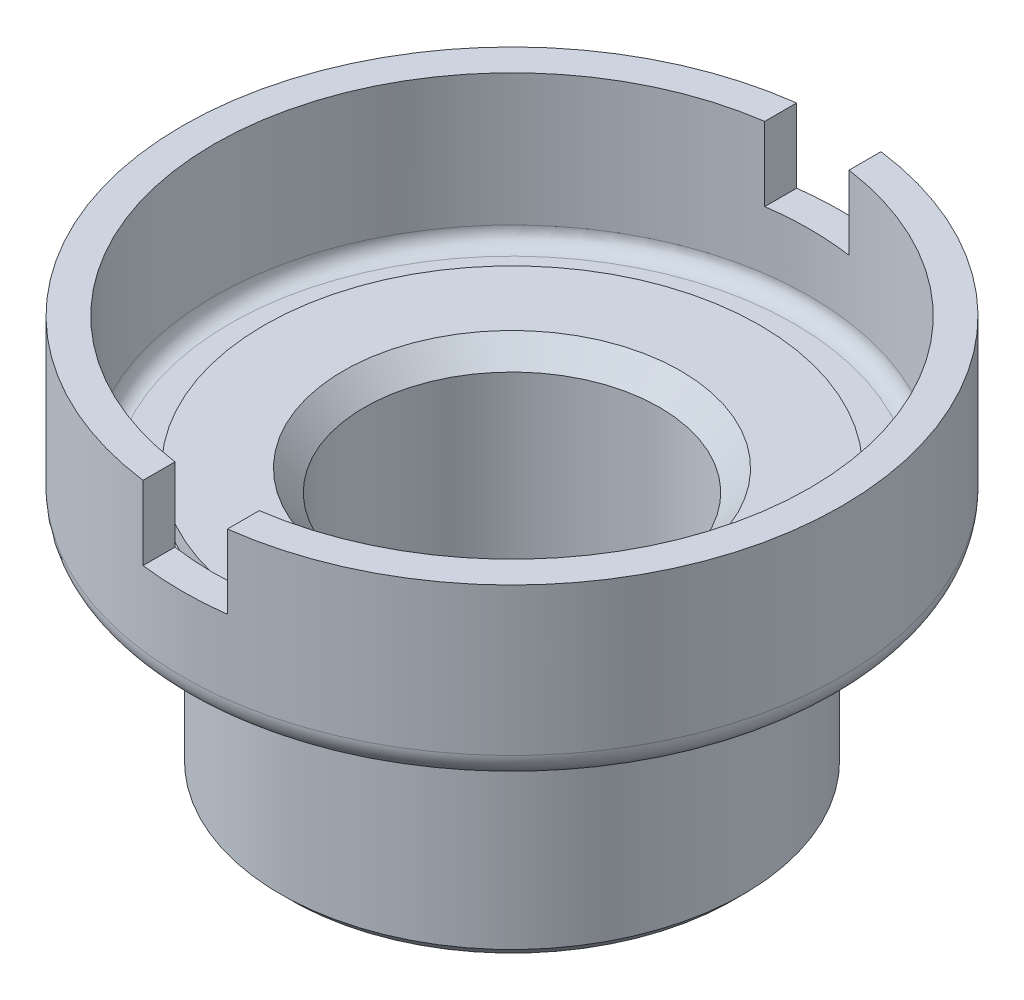
from build123d import *

# Parameters (mm, degrees)
SKETCH2_W          = 16
SKETCH2_H          = 14
CUT_EXTRUDE1_DEPTH = 110.5


with BuildPart() as part:
    # Sketch1 → Revolve1 (revolve)
    with BuildSketch(Plane.XY):
        with BuildLine():
            Line((-28, 0), (-28, 46))
            Line((-28, 46), (-32, 50))
            Line((-32, 50), (-47, 50))
            Line((-47, 50), (-47, 47))
            Line((-47, 47), (-53.5, 47))
            ThreePointArc((-53.5, 47), (-55.621320344, 47.878679656), (-56.5, 50))
            Line((-56.5, 50), (-56.5, 75))
            Line((-56.5, 75), (-62.5, 75))
            Line((-62.5, 75), (-62.5, 47))
            ThreePointArc((-62.5, 47), (-61.035533906, 43.464466094), (-57.5, 42))
            Line((-57.5, 42), (-43.94, 42))
            Line((-43.94, 42), (-43.94, 2))
            Line((-43.94, 2), (-41.94, 0))
            Line((-41.94, 0), (-28, 0))
        make_face()
    revolve(axis=Axis((0, 0, 0), (0, 1, 0)))

    # Sketch2 → Cut-Extrude1 (cut, symmetric)
    with BuildSketch(Plane.XY):
        with Locations((0, 68)):
            Rectangle(SKETCH2_W, SKETCH2_H)
    extrude(amount=CUT_EXTRUDE1_DEPTH, both=True, mode=Mode.SUBTRACT)


solid = part.part
